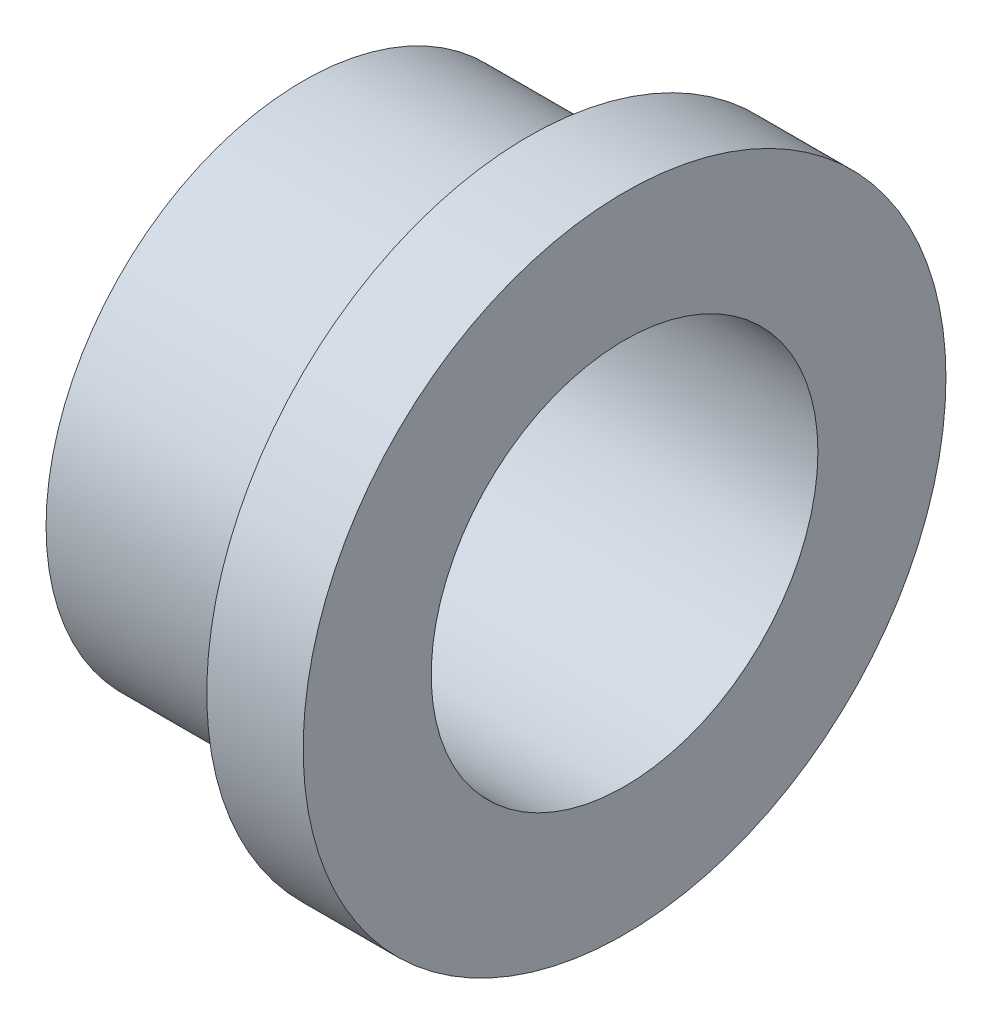
from build123d import *

# Parameters (mm, degrees)
SKETCH1_R           = 12.7
SKETCH1_R_2         = 9.5504
BOSS_EXTRUDE1_DEPTH = 15.875
SKETCH3_R           = 15.875
SKETCH3_R_2         = 9.5504
BOSS_EXTRUDE2_DEPTH = 4.7625


with BuildPart() as part:
    # Sketch1 → Boss-Extrude1 (new body)
    with BuildSketch(Plane(origin=(0, 0, 0), x_dir=(0, 0, -1), z_dir=(1, 0, 0))):
        Circle(SKETCH1_R)
        Circle(SKETCH1_R_2, mode=Mode.SUBTRACT)
    extrude(amount=-BOSS_EXTRUDE1_DEPTH)

    # Sketch3 → Boss-Extrude2 (add)
    with BuildSketch(Plane(origin=(0, 0, 0), x_dir=(0, 0, -1), z_dir=(1, 0, 0))):
        Circle(SKETCH3_R)
        Circle(SKETCH3_R_2, mode=Mode.SUBTRACT)
    extrude(amount=-BOSS_EXTRUDE2_DEPTH)


solid = part.part
